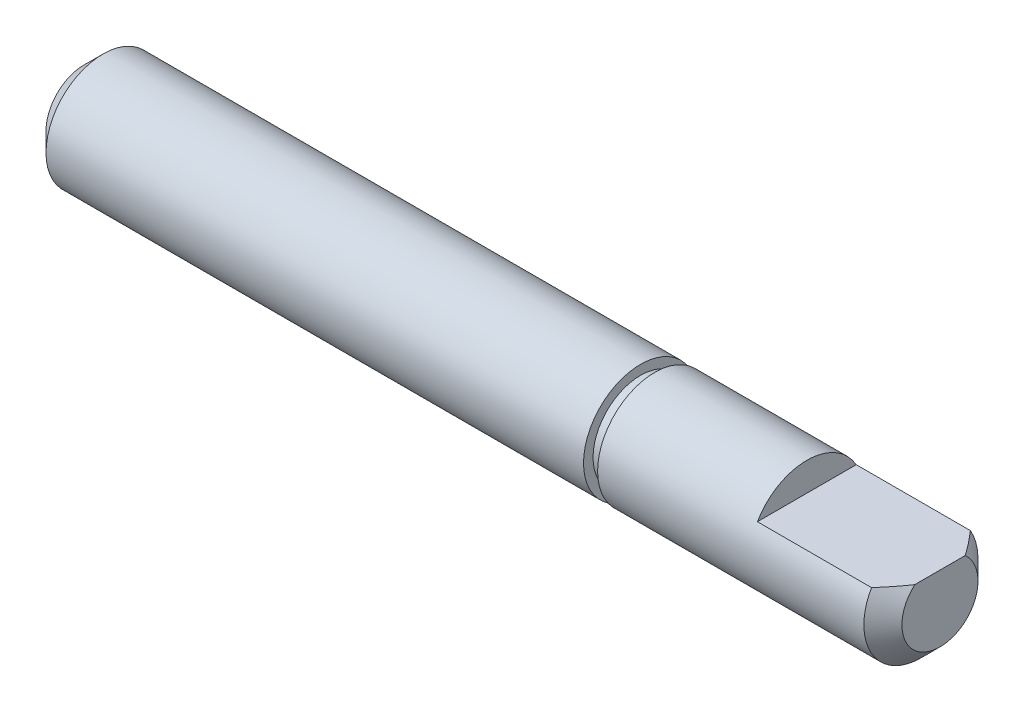
from build123d import *

# Parameters (mm, degrees)
ESQUISSE2_W             = 7.209705372
ESQUISSE2_H             = 2.76140959
ENL_V_MAT_EXTRU_1_DEPTH = 7


with BuildPart() as part:
    # Esquisse1 → Révolution1 (revolve)
    with BuildSketch(Plane.XY, mode=Mode.PRIVATE) as r_volution1_sk:
        Polygon((0, 0), (0, 2), (1, 3), (29.26, 3), (29.26, 2.5), (30, 2.5), (30, 3), (44, 3), (45, 2), (45, 0), align=None)
    revolve(r_volution1_sk.sketch.rotate(Axis((-55.939428076, 0, 0), (1, 0, 0)), 90), axis=Axis((-55.939428076, 0, 0), (1, 0, 0)))  # turned: the seam where the file's is

    # Esquisse2 → Enlèv. mat.-Extru.1 (cut)
    with BuildSketch(Plane(origin=(45, 0, 0), x_dir=(0, 0, -1), z_dir=(1, 0, 0))):
        with Locations((-0.271519353, 2.880704795)):
            Rectangle(ESQUISSE2_W, ESQUISSE2_H)
    extrude(amount=-ENL_V_MAT_EXTRU_1_DEPTH, mode=Mode.SUBTRACT)


solid = part.part
